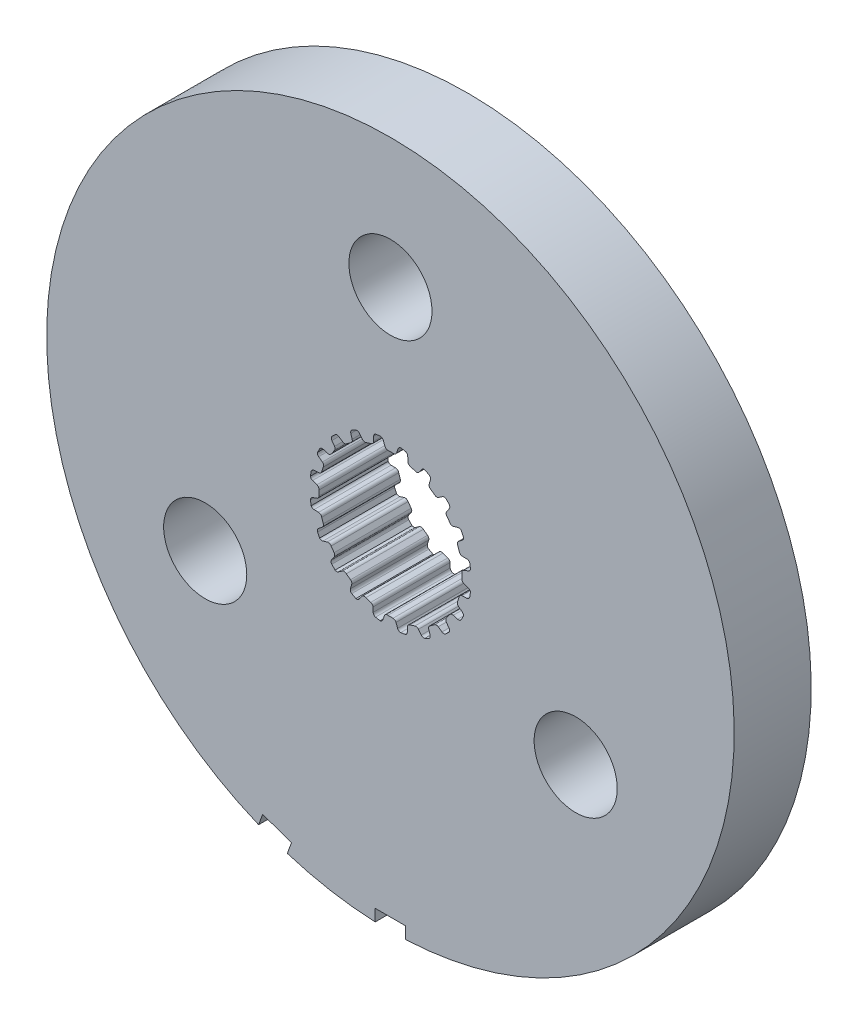
from build123d import *

# Parameters (mm, degrees)
SKETCH1_R           = 14.2875
BOSS_EXTRUDE1_DEPTH = 3.2004
SKETCH5_R           = 1.7272
CUT_EXTRUDE2_DEPTH  = 3.2004
SKETCH7_W           = 1.27
SKETCH7_H           = 0.508
CUT_EXTRUDE3_DEPTH  = 3.2004


with BuildPart() as part:
    # Sketch1 → Boss-Extrude1 (new body)
    with BuildSketch(Plane.XY):
        Circle(SKETCH1_R)
        with BuildLine():
            Line((-0.106949245, 2.969874934), (0.106949245, 2.969874934))
            ThreePointArc((0.106949245, 2.969874934), (0.196343213, 2.986924176), (0.253739238, 3.057547504))
            Line((0.253739238, 3.057547504), (0.315888147, 3.237526941))
            ThreePointArc((0.315888147, 3.237526941), (0.359032156, 3.298322911), (0.4281449, 3.326269005))
            Line((0.4281449, 3.326269005), (0.620027588, 3.2937547))
            ThreePointArc((0.620027588, 3.2937547), (0.689621142, 3.24802576), (0.718272212, 3.169836791))
            Line((0.718272212, 3.169836791), (0.724389167, 2.979527391))
            ThreePointArc((0.724389167, 2.979527391), (0.750934762, 2.9040661), (0.816027049, 2.857568043))
            Line((0.816027049, 2.857568043), (1.019456602, 2.791469774))
            ThreePointArc((1.019456602, 2.791469774), (1.109743823, 2.780060312), (1.186154496, 2.829490741))
            Line((1.186154496, 2.829490741), (1.300878326, 2.981456288))
            ThreePointArc((1.300878326, 2.981456288), (1.360697704, 3.02594446), (1.435063648, 3.031165762))
            Line((1.435063648, 3.031165762), (1.607507455, 2.940947809))
            ThreePointArc((1.607507455, 2.940947809), (1.659563839, 2.875951412), (1.662650905, 2.792735615))
            Line((1.662650905, 2.792735615), (1.609659636, 2.609850378))
            ThreePointArc((1.609659636, 2.609850378), (1.611587176, 2.529879385), (1.659124931, 2.465542482))
            Line((1.659124931, 2.465542482), (1.832172444, 2.339816104))
            ThreePointArc((1.832172444, 2.339816104), (1.914514976, 2.301064775), (2.002460687, 2.32446371))
            Line((2.002460687, 2.32446371), (2.158529469, 2.433539921))
            ThreePointArc((2.158529469, 2.433539921), (2.229168681, 2.457365482), (2.301508367, 2.439350895))
            Line((2.301508367, 2.439350895), (2.437633293, 2.300260456))
            ThreePointArc((2.437633293, 2.300260456), (2.467056864, 2.222358901), (2.444277744, 2.14226202))
            Line((2.444277744, 2.14226202), (2.337365406, 1.984703026))
            ThreePointArc((2.337365406, 1.984703026), (2.314486209, 1.908050449), (2.339816104, 1.832172444))
            Line((2.339816104, 1.832172444), (2.465542482, 1.659124931))
            ThreePointArc((2.465542482, 1.659124931), (2.531880064, 1.596824985), (2.622752074, 1.591901975))
            Line((2.622752074, 1.591901975), (2.804888709, 1.64741171))
            ThreePointArc((2.804888709, 1.64741171), (2.879433095, 1.648242449), (2.942665411, 1.608755366))
            Line((2.942665411, 1.608755366), (3.0291466, 1.434407582))
            ThreePointArc((3.0291466, 1.434407582), (3.033057175, 1.351226417), (2.986641646, 1.282088892))
            Line((2.986641646, 1.282088892), (2.836273564, 1.165279113))
            ThreePointArc((2.836273564, 1.165279113), (2.790827206, 1.099448241), (2.791469774, 1.019456602))
            Line((2.791469774, 1.019456602), (2.857568043, 0.816027049))
            ThreePointArc((2.857568043, 0.816027049), (2.901407091, 0.736276839), (2.986310214, 0.703513784))
            Line((2.986310214, 0.703513784), (3.1766859, 0.700023363))
            ThreePointArc((3.1766859, 0.700023363), (3.247838536, 0.677777961), (3.295773863, 0.620683653))
            Line((3.295773863, 0.620683653), (3.324145932, 0.4281449))
            ThreePointArc((3.324145932, 0.4281449), (3.302160717, 0.347826477), (3.236652255, 0.29641597))
            Line((3.236652255, 0.29641597), (3.057547504, 0.231789562))
            ThreePointArc((3.057547504, 0.231789562), (2.993982591, 0.183224379), (2.969874934, 0.106949245))
            Line((2.969874934, 0.106949245), (2.969874934, -0.106949245))
            ThreePointArc((2.969874934, -0.106949245), (2.986924176, -0.196343213), (3.057547504, -0.253739238))
            Line((3.057547504, -0.253739238), (3.237526941, -0.315888147))
            ThreePointArc((3.237526941, -0.315888147), (3.298322911, -0.359032156), (3.326269005, -0.4281449))
            Line((3.326269005, -0.4281449), (3.2937547, -0.620027588))
            ThreePointArc((3.2937547, -0.620027588), (3.24802576, -0.689621142), (3.169836791, -0.718272212))
            Line((3.169836791, -0.718272212), (2.979527391, -0.724389167))
            ThreePointArc((2.979527391, -0.724389167), (2.9040661, -0.750934762), (2.857568043, -0.816027049))
            Line((2.857568043, -0.816027049), (2.791469774, -1.019456602))
            ThreePointArc((2.791469774, -1.019456602), (2.780060312, -1.109743823), (2.829490741, -1.186154496))
            Line((2.829490741, -1.186154496), (2.981456288, -1.300878326))
            ThreePointArc((2.981456288, -1.300878326), (3.02594446, -1.360697704), (3.031165762, -1.435063648))
            Line((3.031165762, -1.435063648), (2.940947809, -1.607507455))
            ThreePointArc((2.940947809, -1.607507455), (2.875951412, -1.659563839), (2.792735615, -1.662650905))
            Line((2.792735615, -1.662650905), (2.609850378, -1.609659636))
            ThreePointArc((2.609850378, -1.609659636), (2.529879385, -1.611587176), (2.465542482, -1.659124931))
            Line((2.465542482, -1.659124931), (2.339816104, -1.832172444))
            ThreePointArc((2.339816104, -1.832172444), (2.301064775, -1.914514976), (2.32446371, -2.002460687))
            Line((2.32446371, -2.002460687), (2.433539921, -2.158529469))
            ThreePointArc((2.433539921, -2.158529469), (2.457365482, -2.229168681), (2.439350895, -2.301508367))
            Line((2.439350895, -2.301508367), (2.300260456, -2.437633293))
            ThreePointArc((2.300260456, -2.437633293), (2.222358901, -2.467056864), (2.14226202, -2.444277744))
            Line((2.14226202, -2.444277744), (1.984703026, -2.337365406))
            ThreePointArc((1.984703026, -2.337365406), (1.908050449, -2.314486209), (1.832172444, -2.339816104))
            Line((1.832172444, -2.339816104), (1.659124931, -2.465542482))
            ThreePointArc((1.659124931, -2.465542482), (1.596824985, -2.531880064), (1.591901975, -2.622752074))
            Line((1.591901975, -2.622752074), (1.64741171, -2.804888709))
            ThreePointArc((1.64741171, -2.804888709), (1.648242449, -2.879433095), (1.608755366, -2.942665411))
            Line((1.608755366, -2.942665411), (1.434407582, -3.0291466))
            ThreePointArc((1.434407582, -3.0291466), (1.351226417, -3.033057175), (1.282088892, -2.986641646))
            Line((1.282088892, -2.986641646), (1.165279113, -2.836273564))
            ThreePointArc((1.165279113, -2.836273564), (1.099448241, -2.790827206), (1.019456602, -2.791469774))
            Line((1.019456602, -2.791469774), (0.816027049, -2.857568043))
            ThreePointArc((0.816027049, -2.857568043), (0.736276839, -2.901407091), (0.703513784, -2.986310214))
            Line((0.703513784, -2.986310214), (0.700023363, -3.1766859))
            ThreePointArc((0.700023363, -3.1766859), (0.677777961, -3.247838536), (0.620683653, -3.295773863))
            Line((0.620683653, -3.295773863), (0.4281449, -3.324145932))
            ThreePointArc((0.4281449, -3.324145932), (0.347826477, -3.302160717), (0.29641597, -3.236652255))
            Line((0.29641597, -3.236652255), (0.231789562, -3.057547504))
            ThreePointArc((0.231789562, -3.057547504), (0.183224379, -2.993982591), (0.106949245, -2.969874934))
            Line((0.106949245, -2.969874934), (-0.106949245, -2.969874934))
            ThreePointArc((-0.106949245, -2.969874934), (-0.196343213, -2.986924176), (-0.253739238, -3.057547504))
            Line((-0.253739238, -3.057547504), (-0.315888147, -3.237526941))
            ThreePointArc((-0.315888147, -3.237526941), (-0.359032156, -3.298322911), (-0.4281449, -3.326269005))
            Line((-0.4281449, -3.326269005), (-0.620027588, -3.2937547))
            ThreePointArc((-0.620027588, -3.2937547), (-0.689621142, -3.24802576), (-0.718272212, -3.169836791))
            Line((-0.718272212, -3.169836791), (-0.724389167, -2.979527391))
            ThreePointArc((-0.724389167, -2.979527391), (-0.750934762, -2.9040661), (-0.816027049, -2.857568043))
            Line((-0.816027049, -2.857568043), (-1.019456602, -2.791469774))
            ThreePointArc((-1.019456602, -2.791469774), (-1.109743823, -2.780060312), (-1.186154496, -2.829490741))
            Line((-1.186154496, -2.829490741), (-1.300878326, -2.981456288))
            ThreePointArc((-1.300878326, -2.981456288), (-1.360697704, -3.02594446), (-1.435063648, -3.031165762))
            Line((-1.435063648, -3.031165762), (-1.607507455, -2.940947809))
            ThreePointArc((-1.607507455, -2.940947809), (-1.659563839, -2.875951412), (-1.662650905, -2.792735615))
            Line((-1.662650905, -2.792735615), (-1.609659636, -2.609850378))
            ThreePointArc((-1.609659636, -2.609850378), (-1.611587176, -2.529879385), (-1.659124931, -2.465542482))
            Line((-1.659124931, -2.465542482), (-1.832172444, -2.339816104))
            ThreePointArc((-1.832172444, -2.339816104), (-1.914514976, -2.301064775), (-2.002460687, -2.32446371))
            Line((-2.002460687, -2.32446371), (-2.158529469, -2.433539921))
            ThreePointArc((-2.158529469, -2.433539921), (-2.229168681, -2.457365482), (-2.301508367, -2.439350895))
            Line((-2.301508367, -2.439350895), (-2.437633293, -2.300260456))
            ThreePointArc((-2.437633293, -2.300260456), (-2.467056864, -2.222358901), (-2.444277744, -2.14226202))
            Line((-2.444277744, -2.14226202), (-2.337365406, -1.984703026))
            ThreePointArc((-2.337365406, -1.984703026), (-2.314486209, -1.908050449), (-2.339816104, -1.832172444))
            Line((-2.339816104, -1.832172444), (-2.465542482, -1.659124931))
            ThreePointArc((-2.465542482, -1.659124931), (-2.531880064, -1.596824985), (-2.622752074, -1.591901975))
            Line((-2.622752074, -1.591901975), (-2.804888709, -1.64741171))
            ThreePointArc((-2.804888709, -1.64741171), (-2.879433095, -1.648242449), (-2.942665411, -1.608755366))
            Line((-2.942665411, -1.608755366), (-3.0291466, -1.434407582))
            ThreePointArc((-3.0291466, -1.434407582), (-3.033057175, -1.351226417), (-2.986641646, -1.282088892))
            Line((-2.986641646, -1.282088892), (-2.836273564, -1.165279113))
            ThreePointArc((-2.836273564, -1.165279113), (-2.790827206, -1.099448241), (-2.791469774, -1.019456602))
            Line((-2.791469774, -1.019456602), (-2.857568043, -0.816027049))
            ThreePointArc((-2.857568043, -0.816027049), (-2.901407091, -0.736276839), (-2.986310214, -0.703513784))
            Line((-2.986310214, -0.703513784), (-3.1766859, -0.700023363))
            ThreePointArc((-3.1766859, -0.700023363), (-3.247838536, -0.677777961), (-3.295773863, -0.620683653))
            Line((-3.295773863, -0.620683653), (-3.324145932, -0.4281449))
            ThreePointArc((-3.324145932, -0.4281449), (-3.302160717, -0.347826477), (-3.236652255, -0.29641597))
            Line((-3.236652255, -0.29641597), (-3.057547504, -0.231789562))
            ThreePointArc((-3.057547504, -0.231789562), (-2.993982591, -0.183224379), (-2.969874934, -0.106949245))
            Line((-2.969874934, -0.106949245), (-2.969874934, 0.106949245))
            ThreePointArc((-2.969874934, 0.106949245), (-2.986924176, 0.196343213), (-3.057547504, 0.253739238))
            Line((-3.057547504, 0.253739238), (-3.237526941, 0.315888147))
            ThreePointArc((-3.237526941, 0.315888147), (-3.298322911, 0.359032156), (-3.326269005, 0.4281449))
            Line((-3.326269005, 0.4281449), (-3.2937547, 0.620027588))
            ThreePointArc((-3.2937547, 0.620027588), (-3.24802576, 0.689621142), (-3.169836791, 0.718272212))
            Line((-3.169836791, 0.718272212), (-2.979527391, 0.724389167))
            ThreePointArc((-2.979527391, 0.724389167), (-2.9040661, 0.750934762), (-2.857568043, 0.816027049))
            Line((-2.857568043, 0.816027049), (-2.791469774, 1.019456602))
            ThreePointArc((-2.791469774, 1.019456602), (-2.780060312, 1.109743823), (-2.829490741, 1.186154496))
            Line((-2.829490741, 1.186154496), (-2.981456288, 1.300878326))
            ThreePointArc((-2.981456288, 1.300878326), (-3.02594446, 1.360697704), (-3.031165762, 1.435063648))
            Line((-3.031165762, 1.435063648), (-2.940947809, 1.607507455))
            ThreePointArc((-2.940947809, 1.607507455), (-2.875951412, 1.659563839), (-2.792735615, 1.662650905))
            Line((-2.792735615, 1.662650905), (-2.609850378, 1.609659636))
            ThreePointArc((-2.609850378, 1.609659636), (-2.529879385, 1.611587176), (-2.465542482, 1.659124931))
            Line((-2.465542482, 1.659124931), (-2.339816104, 1.832172444))
            ThreePointArc((-2.339816104, 1.832172444), (-2.301064775, 1.914514976), (-2.32446371, 2.002460687))
            Line((-2.32446371, 2.002460687), (-2.433539921, 2.158529469))
            ThreePointArc((-2.433539921, 2.158529469), (-2.457365482, 2.229168681), (-2.439350895, 2.301508367))
            Line((-2.439350895, 2.301508367), (-2.300260456, 2.437633293))
            ThreePointArc((-2.300260456, 2.437633293), (-2.222358901, 2.467056864), (-2.14226202, 2.444277744))
            Line((-2.14226202, 2.444277744), (-1.984703026, 2.337365406))
            ThreePointArc((-1.984703026, 2.337365406), (-1.908050449, 2.314486209), (-1.832172444, 2.339816104))
            Line((-1.832172444, 2.339816104), (-1.659124931, 2.465542482))
            ThreePointArc((-1.659124931, 2.465542482), (-1.596824985, 2.531880064), (-1.591901975, 2.622752074))
            Line((-1.591901975, 2.622752074), (-1.64741171, 2.804888709))
            ThreePointArc((-1.64741171, 2.804888709), (-1.648242449, 2.879433095), (-1.608755366, 2.942665411))
            Line((-1.608755366, 2.942665411), (-1.434407582, 3.0291466))
            ThreePointArc((-1.434407582, 3.0291466), (-1.351226417, 3.033057175), (-1.282088892, 2.986641646))
            Line((-1.282088892, 2.986641646), (-1.165279113, 2.836273564))
            ThreePointArc((-1.165279113, 2.836273564), (-1.099448241, 2.790827206), (-1.019456602, 2.791469774))
            Line((-1.019456602, 2.791469774), (-0.816027049, 2.857568043))
            ThreePointArc((-0.816027049, 2.857568043), (-0.736276839, 2.901407091), (-0.703513784, 2.986310214))
            Line((-0.703513784, 2.986310214), (-0.700023363, 3.1766859))
            ThreePointArc((-0.700023363, 3.1766859), (-0.677777961, 3.247838536), (-0.620683653, 3.295773863))
            Line((-0.620683653, 3.295773863), (-0.4281449, 3.324145932))
            ThreePointArc((-0.4281449, 3.324145932), (-0.347826477, 3.302160717), (-0.29641597, 3.236652255))
            Line((-0.29641597, 3.236652255), (-0.231789562, 3.057547504))
            ThreePointArc((-0.231789562, 3.057547504), (-0.183224379, 2.993982591), (-0.106949245, 2.969874934))
        make_face(mode=Mode.SUBTRACT)
    extrude(amount=BOSS_EXTRUDE1_DEPTH)

    # Sketch5 → Cut-Extrude2 (cut)
    with BuildSketch(Plane.XY.offset(3.2004)):
        with Locations((0, 8.89)):
            Circle(SKETCH5_R)
        with Locations((7.69896584, -4.445)):
            Circle(SKETCH5_R)
        with Locations((-7.69896584, -4.445)):
            Circle(SKETCH5_R)
    extrude(amount=-CUT_EXTRUDE2_DEPTH, mode=Mode.SUBTRACT)

    # Sketch7 → Cut-Extrude3 (cut)
    with BuildSketch(Plane.XY.offset(3.2004)):
        Polygon((-4.289907984, -13.64304111), (-4.116161751, -13.165677259), (-5.309571379, -12.731311677), (-5.483317612, -13.208675528), align=None)
        with Locations((0, -14.0335)):
            Rectangle(SKETCH7_W, SKETCH7_H)
    extrude(amount=-CUT_EXTRUDE3_DEPTH, mode=Mode.SUBTRACT)


solid = part.part
